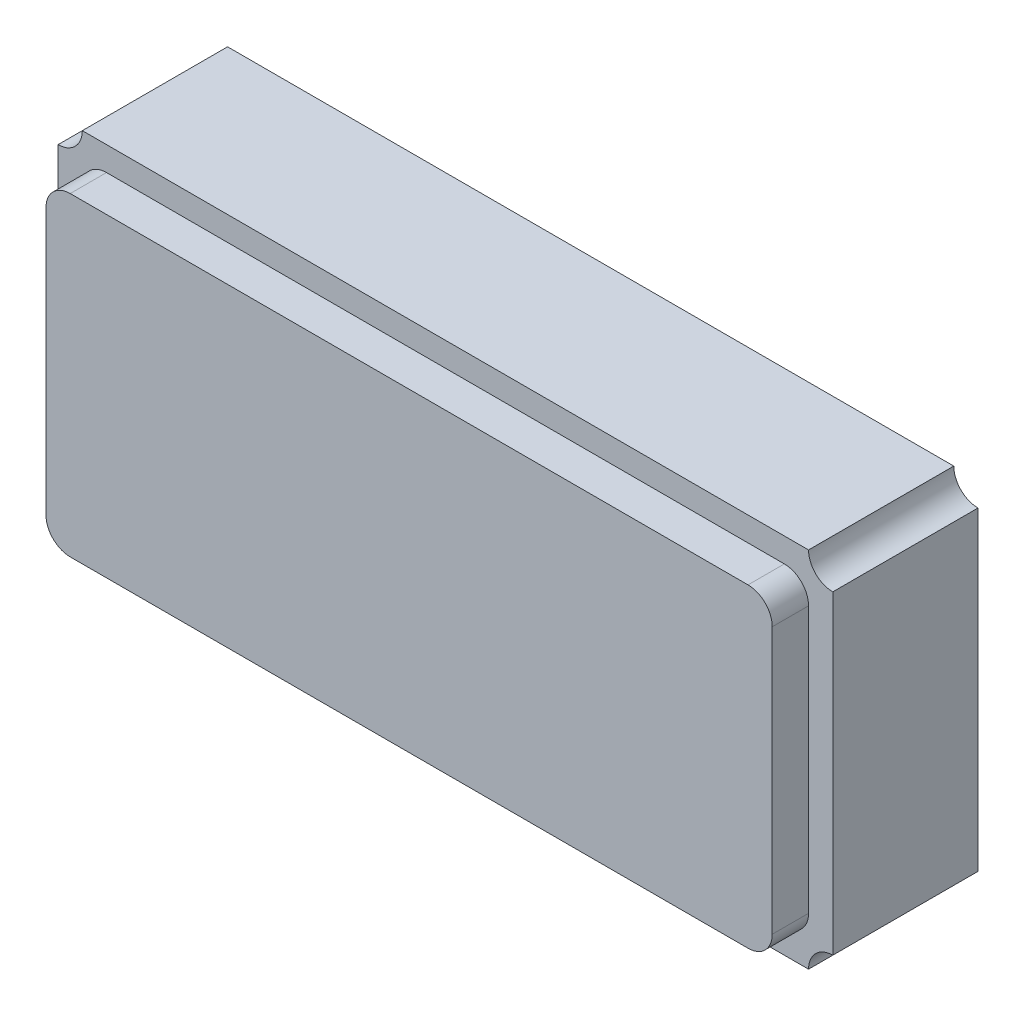
from build123d import *

# Parameters (mm, degrees)
BOSS_EXTRUDE1_DEPTH = 0.6
SKETCH2_W           = 3
SKETCH2_H           = 1.3
BOSS_EXTRUDE2_DEPTH = 0.15
FILLET1_R           = 0.1


with BuildPart() as part:
    # Sketch1 → Boss-Extrude1 (new body)
    with BuildSketch(Plane.XY):
        with BuildLine():
            Line((0.099997141, 0), (3.100008577, 0))
            ThreePointArc((3.100008577, 0), (3.129296051, 0.070707646), (3.200002859, 0.099997141))
            Line((3.200002859, 0.099997141), (3.200002859, 1.400002859))
            ThreePointArc((3.200002859, 1.400002859), (3.129292354, 1.429290333), (3.100002859, 1.5))
            Line((3.100002859, 1.5), (0.100002859, 1.5))
            ThreePointArc((0.100002859, 1.5), (0.0707127, 1.4292873), (0, 1.399997141))
            Line((0, 1.399997141), (0, 0.099997141))
            ThreePointArc((0, 0.099997141), (0.070708656, 0.070708656), (0.099997141, 0))
        make_face()
    extrude(amount=BOSS_EXTRUDE1_DEPTH)

    # Sketch2 → Boss-Extrude2 (add)
    with BuildSketch(Plane.XY.offset(0.6)):
        with Locations((1.600002859, 0.749997141)):
            Rectangle(SKETCH2_W, SKETCH2_H)
    extrude(amount=BOSS_EXTRUDE2_DEPTH)

    # Fillet1
    fillet1_edges = [part.edges().sort_by_distance(p)[0] for p in [
        (0.100002859, 1.399997141, 0.675),
        (0.100002859, 0.099997141, 0.675),
        (3.100002859, 0.099997141, 0.675),
        (3.100002859, 1.399997141, 0.675),
    ]]
    fillet(fillet1_edges, radius=FILLET1_R)


solid = part.part
